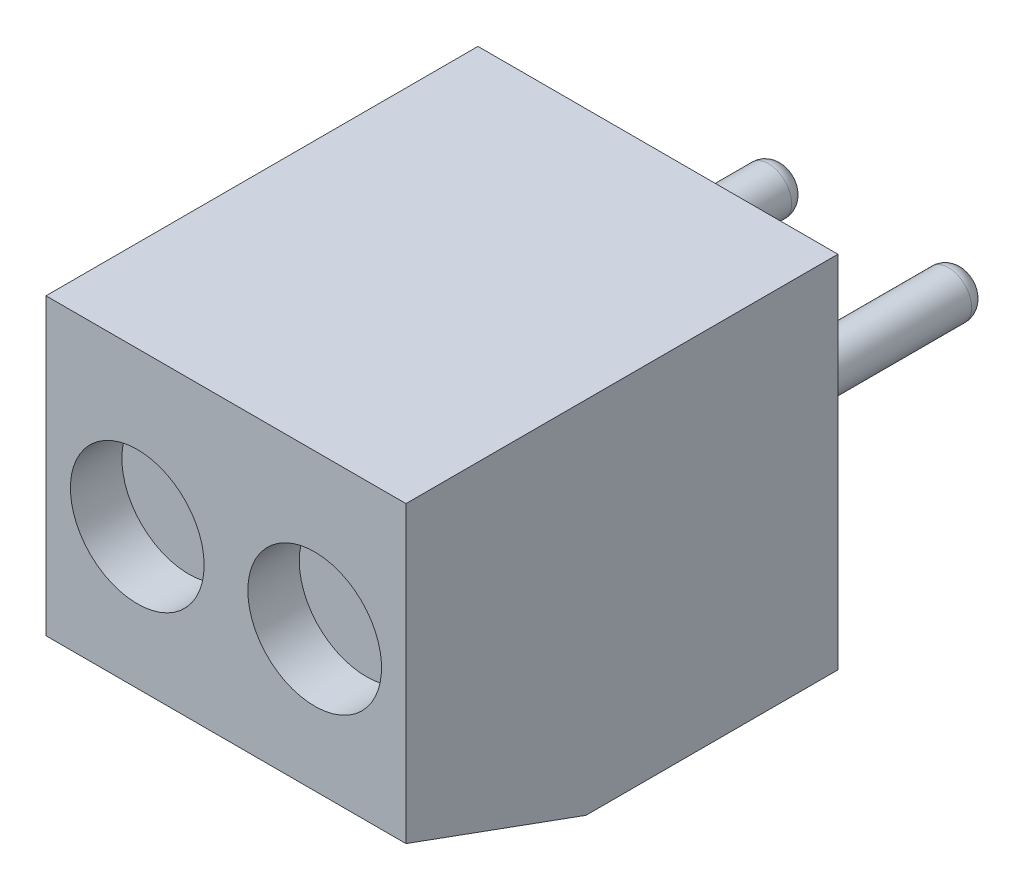
from build123d import *

# Parameters (mm, degrees)
SKETCH1_W           = 7
SKETCH1_H           = 7
BOSS_EXTRUDE1_DEPTH = 8.4
CHAMFER1_SIZE       = 3.5
CHAMFER1_SIZE2      = 1.27389582
SKETCH2_W           = 2.85
SKETCH2_H           = 4.2
CUT_EXTRUDE1_DEPTH  = 1.8
SKETCH3_R           = 1
CUT_EXTRUDE2_DEPTH  = 4.2
SKETCH4_R           = 1.3
CUT_EXTRUDE3_DEPTH  = 1
SKETCH5_R           = 0.45
BOSS_EXTRUDE2_DEPTH = 4.2
FILLET1_R           = 0.3


with BuildPart() as part:
    # Sketch1 → Boss-Extrude1 (new body)
    with BuildSketch(Plane.XY):
        Rectangle(SKETCH1_W, SKETCH1_H)
    extrude(amount=BOSS_EXTRUDE1_DEPTH)

    # Chamfer1
    chamfer1_edges = [part.edges().sort_by_distance(p)[0] for p in [
        (0, -3.5, 8.4),
    ]]
    chamfer1_side = [part.faces().sort_by_distance(p)[0] for p in [
        (0, -3.5, 4.2),
    ]]
    chamfer(chamfer1_edges, length=CHAMFER1_SIZE, length2=CHAMFER1_SIZE2, reference=chamfer1_side[0])

    # Sketch2 → Cut-Extrude1 (cut)
    with BuildSketch(Plane.XZ.offset(3.5)):
        with Locations((1.725, 2.6)):
            Rectangle(SKETCH2_W, SKETCH2_H)
        with Locations((-1.725, 2.6)):
            Rectangle(SKETCH2_W, SKETCH2_H)
    extrude(amount=-CUT_EXTRUDE1_DEPTH, mode=Mode.SUBTRACT)

    # Sketch3 → Cut-Extrude2 (cut)
    with BuildSketch(Plane.XZ.offset(1.7)):
        with Locations((-1.725, 2.6)):
            Circle(SKETCH3_R)
        with Locations((1.725, 2.6)):
            Circle(SKETCH3_R)
    extrude(amount=-CUT_EXTRUDE2_DEPTH, mode=Mode.SUBTRACT)

    # Sketch4 → Cut-Extrude3 (cut)
    with BuildSketch(Plane.XY.offset(8.4)):
        with Locations((-1.725, 0.5)):
            Circle(SKETCH4_R)
        with Locations((1.725, 0.5)):
            Circle(SKETCH4_R)
    extrude(amount=-CUT_EXTRUDE3_DEPTH, mode=Mode.SUBTRACT)

    # Sketch5 → Boss-Extrude2 (add)
    with BuildSketch(Plane(origin=(0, 0, 0), x_dir=(-1, 0, 0), z_dir=(0, 0, -1))):
        with Locations((-1.75, 0)):
            Circle(SKETCH5_R)
        with Locations((1.75, 0)):
            Circle(SKETCH5_R)
    extrude(amount=BOSS_EXTRUDE2_DEPTH)

    # Fillet1
    fillet1_edges = [part.edges().sort_by_distance(p)[0] for p in [
        (2.2, 0, -4.2),
        (-1.3, 0, -4.2),
    ]]
    fillet(fillet1_edges, radius=FILLET1_R)


solid = part.part
